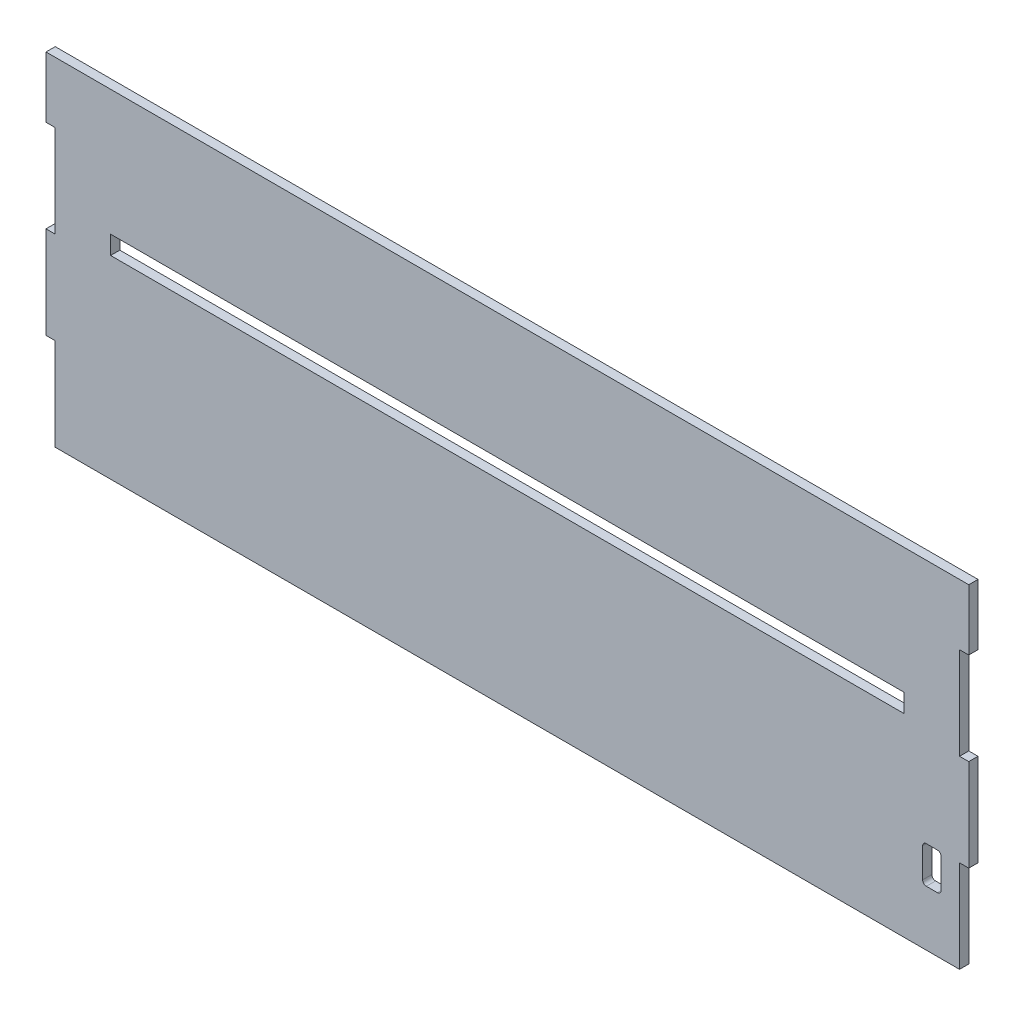
from build123d import *

# Parameters (mm, degrees)
ESQUISSE1_W             = 430
ESQUISSE1_H             = 10
BOSS_EXTRU_1_DEPTH      = 5
ENL_V_MAT_EXTRU_1_REACH = 7


with BuildPart() as part:
    # Esquisse1 → Boss.-Extru.1 (new body)
    with BuildSketch(Plane.XY):
        Polygon((0, 50), (5, 50), (5, 0), (495, 0), (495, 50), (500, 50), (500, 100), (495, 100), (495, 150), (500, 150), (500, 183), (0, 183), (0, 150), (5, 150), (5, 100), (0, 100), align=None)
        with Locations((250, 110)):
            Rectangle(ESQUISSE1_W, ESQUISSE1_H, mode=Mode.SUBTRACT)
    extrude(amount=BOSS_EXTRU_1_DEPTH)

    # Esquisse2 → Enlèv. mat.-Extru.1 (cut, up to next)
    with BuildSketch(Plane(origin=(0, 0, 0), x_dir=(-1, 0, 0), z_dir=(0, 0, -1)), mode=Mode.PRIVATE) as enl_v_mat_extru_1_sk1:
        with BuildLine():
            Line((-483, 30), (-477, 30))
            ThreePointArc((-477, 30), (-475.585786438, 30.585786438), (-475, 32))
            Line((-475, 32), (-475, 48))
            ThreePointArc((-475, 48), (-475.585786438, 49.414213562), (-477, 50))
            Line((-477, 50), (-483, 50))
            ThreePointArc((-483, 50), (-484.414213562, 49.414213562), (-485, 48))
            Line((-485, 48), (-485, 32))
            ThreePointArc((-485, 32), (-484.414213562, 30.585786438), (-483, 30))
        make_face()
    enl_v_mat_extru_1_tool1 = extrude(enl_v_mat_extru_1_sk1.sketch, amount=-ENL_V_MAT_EXTRU_1_REACH, mode=Mode.PRIVATE) & part.part
    add(enl_v_mat_extru_1_tool1.solids().sort_by_distance((480, 40, 0))[0], mode=Mode.SUBTRACT)


solid = part.part
